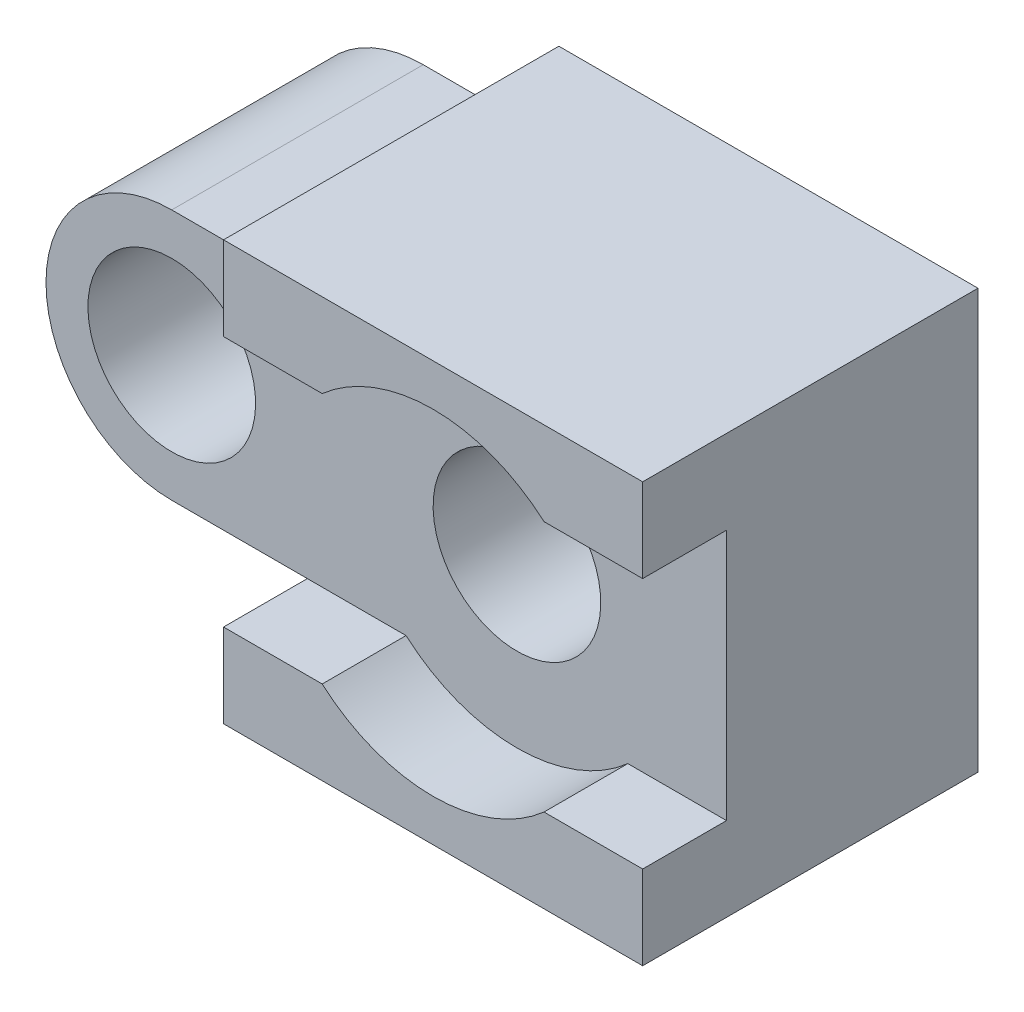
from build123d import *

# Parameters (mm, degrees)
SKETCH1_R           = 2
BOSS_EXTRUDE1_DEPTH = 8
SKETCH2_W           = 2
SKETCH2_H           = 6
CUT_EXTRUDE1_DEPTH  = 18
SKETCH3_R           = 4
CUT_EXTRUDE2_DEPTH  = 36


with BuildPart() as part:
    # Sketch1 → Boss-Extrude1 (new body)
    with BuildSketch(Plane.XY):
        with BuildLine():
            Line((-5, 3), (-8.235644223, 3))
            ThreePointArc((-8.235644223, 3), (-10.359234513, 2.119047966), (-11.235637346, -0.006423812))
            ThreePointArc((-11.235637346, -0.006423812), (-10.354692189, -2.12359029), (-8.235644223, -3))
            Line((-8.235644223, -3), (-5, -3))
            Line((-5, -3), (-5, -5))
            Line((-5, -5), (5, -5))
            Line((5, -5), (5, 5))
            Line((5, 5), (-5, 5))
            Line((-5, 5), (-5, 3))
        make_face()
        with Locations((-8.235644223, 0)):
            Circle(SKETCH1_R, mode=Mode.SUBTRACT)
        Circle(SKETCH1_R, mode=Mode.SUBTRACT)
    extrude(amount=BOSS_EXTRUDE1_DEPTH)

    # Sketch2 → Cut-Extrude1 (cut, symmetric)
    with BuildSketch(Plane(origin=(0, 0, 0), x_dir=(0, 0, -1), z_dir=(1, 0, 0))):
        with Locations((-7, 0)):
            Rectangle(SKETCH2_W, SKETCH2_H)
    extrude(amount=CUT_EXTRUDE1_DEPTH, both=True, mode=Mode.SUBTRACT)

    # Sketch3 → Cut-Extrude2 (cut)
    with BuildSketch(Plane.XY.offset(6)):
        Circle(SKETCH3_R)
    extrude(amount=CUT_EXTRUDE2_DEPTH, mode=Mode.SUBTRACT)


solid = part.part
